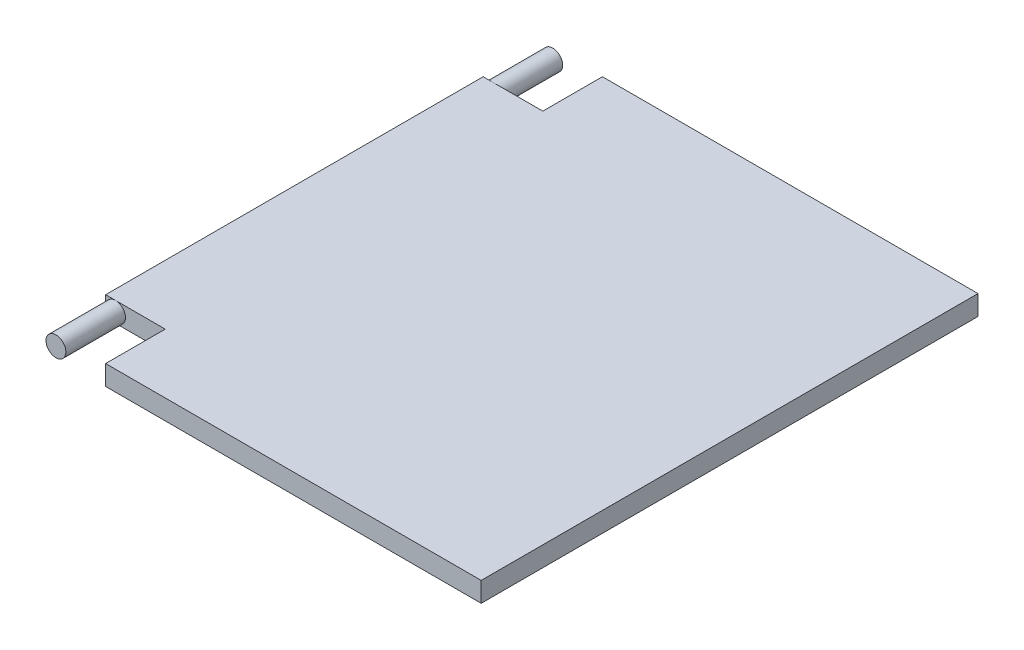
from build123d import *

# Parameters (mm, degrees)
BOSS_EXTRU_1_DEPTH = 10
ESQUISSE2_R        = 5
BOSS_EXTRU_2_DEPTH = 30
ESQUISSE3_R        = 5
BOSS_EXTRU_3_DEPTH = 30


with BuildPart() as part:
    # Esquisse1 → Boss.-Extru.1 (new body)
    with BuildSketch(Plane(origin=(0, 0, 0), x_dir=(1, 0, 0), z_dir=(0, 1, 0))):
        Polygon((0, 0), (189, 0), (189, 250), (0, 250), (0, 220), (-30, 220), (-30, 30), (0, 30), align=None)
    extrude(amount=BOSS_EXTRU_1_DEPTH)

    # Esquisse2 → Boss.-Extru.2 (add)
    with BuildSketch(Plane.XY.offset(-30)):
        with Locations((-25, 5)):
            Circle(ESQUISSE2_R)
    extrude(amount=BOSS_EXTRU_2_DEPTH)

    # Esquisse3 → Boss.-Extru.3 (add)
    with BuildSketch(Plane(origin=(0, 0, -220), x_dir=(-1, 0, 0), z_dir=(0, 0, -1))):
        with Locations((25, 5)):
            Circle(ESQUISSE3_R)
    extrude(amount=BOSS_EXTRU_3_DEPTH)


solid = part.part
